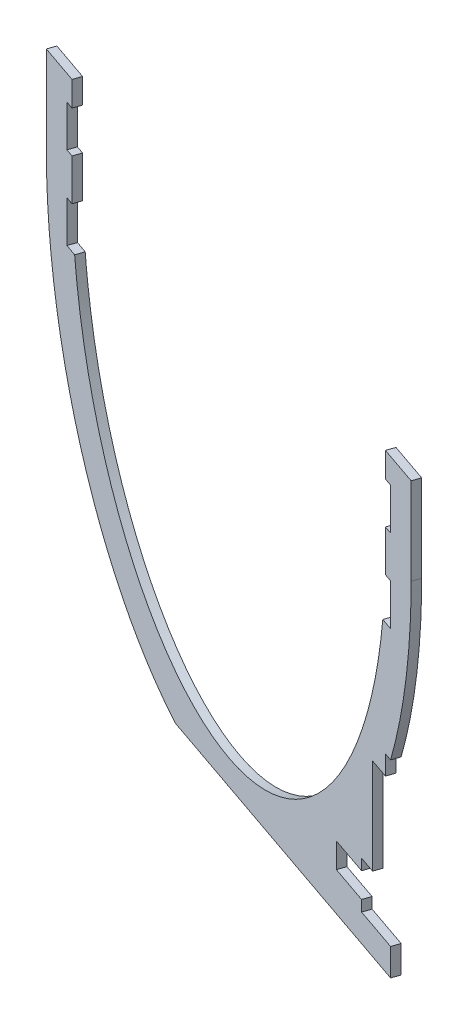
from build123d import *

# Parameters (mm, degrees)
BOSS_EXTRUDE1_DEPTH = 10


with BuildPart() as part:
    # Sketch4 → Boss-Extrude1 (new body)
    with BuildSketch(Plane(origin=(261.301378678, 0, -758.874306307), x_dir=(0.945518576, 0, 0.325568154), z_dir=(-0.325568154, 0, 0.945518576))):
        with BuildLine():
            Line((21.755705622, 515), (21.755705622, 485))
            Line((21.755705622, 485), (31.755705622, 485))
            Line((31.755705622, 485), (31.755705622, 435))
            Line((31.755705622, 435), (21.755705622, 435))
            Line((21.755705622, 435), (21.755705622, 385))
            Line((21.755705622, 385), (31.755705622, 385))
            Line((31.755705622, 385), (31.755705622, 335))
            Line((31.755705622, 335), (21.755705622, 335))
            Line((21.755705622, 335), (16.60929745, 335))
            add(Edge.make_bspline(
                [(-583.097886205, 335), (-536.728774067, 0), (-283.244294378, 0), (-29.759814689, 0), (16.60929745, 335)],
                knots=[4.896351675, 4.896351675, 4.896351675, 6.283185307, 6.283185307, 7.67001894, 7.67001894, 7.67001894], degree=2, weights=[1, 0.769066587, 1, 0.769066587, 1]))
            Line((-583.097886205, 335), (-588.244294378, 335))
            Line((-588.244294378, 335), (-598.244294378, 335))
            Line((-598.244294378, 335), (-598.244294378, 385))
            Line((-598.244294378, 385), (-588.244294378, 385))
            Line((-588.244294378, 385), (-588.244294378, 435))
            Line((-588.244294378, 435), (-598.244294378, 435))
            Line((-598.244294378, 435), (-598.244294378, 485))
            Line((-598.244294378, 485), (-588.244294378, 485))
            Line((-588.244294378, 485), (-588.244294378, 515))
            Line((-588.244294378, 515), (-638.244294378, 515))
            Line((-638.244294378, 515), (-638.244294378, 410))
            add(Edge.make_bspline(
                [(-638.244294378, 410), (-638.244294378, 69.353354952), (-386.783963771, -30)],
                knots=[1.570796327, 1.570796327, 1.570796327, 2.845629732, 2.845629732, 2.845629732], degree=2, weights=[1, 0.803635813, 1]))
            Line((-386.783963771, -30), (-179.704624985, -30))
            Line((-179.704624985, -30), (31.755705622, -30))
            Line((31.755705622, -30), (31.755705622, 2.978733327))
            Line((31.755705622, 2.978733327), (21.755705622, 2.978733327))
            Line((21.755705622, 2.978733327), (-3.244294378, 2.978733327))
            Line((-3.244294378, 2.978733327), (-24.744294378, 2.978733327))
            Line((-24.744294378, 2.978733327), (-24.744294378, 16.178733327))
            Line((-24.744294378, 16.178733327), (-73.744294378, 16.178733327))
            Line((-73.744294378, 16.178733327), (-73.744294378, 46.178733327))
            Line((-73.744294378, 46.178733327), (-24.744294378, 46.178733327))
            Line((-24.744294378, 46.178733327), (-24.744294378, 59.378733327))
            Line((-24.744294378, 59.378733327), (-3.244294378, 59.378733327))
            Line((-3.244294378, 59.378733327), (-3.244294378, 127.221118093))
            Line((-3.244294378, 127.221118093), (-3.244294378, 174.61084571))
            Line((-3.244294378, 174.61084571), (21.755705622, 174.61084571))
            Line((21.755705622, 174.61084571), (21.755705622, 197.872547884))
            Line((21.755705622, 197.872547884), (31.755705622, 197.872547884))
            add(Edge.make_bspline(
                [(31.755705622, 197.872547884), (71.755705622, 297.604111192), (71.755705622, 410)],
                knots=[4.233101976, 4.233101976, 4.233101976, 4.71238898, 4.71238898, 4.71238898], degree=2, weights=[1, 0.971422654, 1]))
            Line((71.755705622, 410), (71.755705622, 515))
            Line((71.755705622, 515), (21.755705622, 515))
        make_face()
    extrude(amount=BOSS_EXTRUDE1_DEPTH)


solid = part.part
